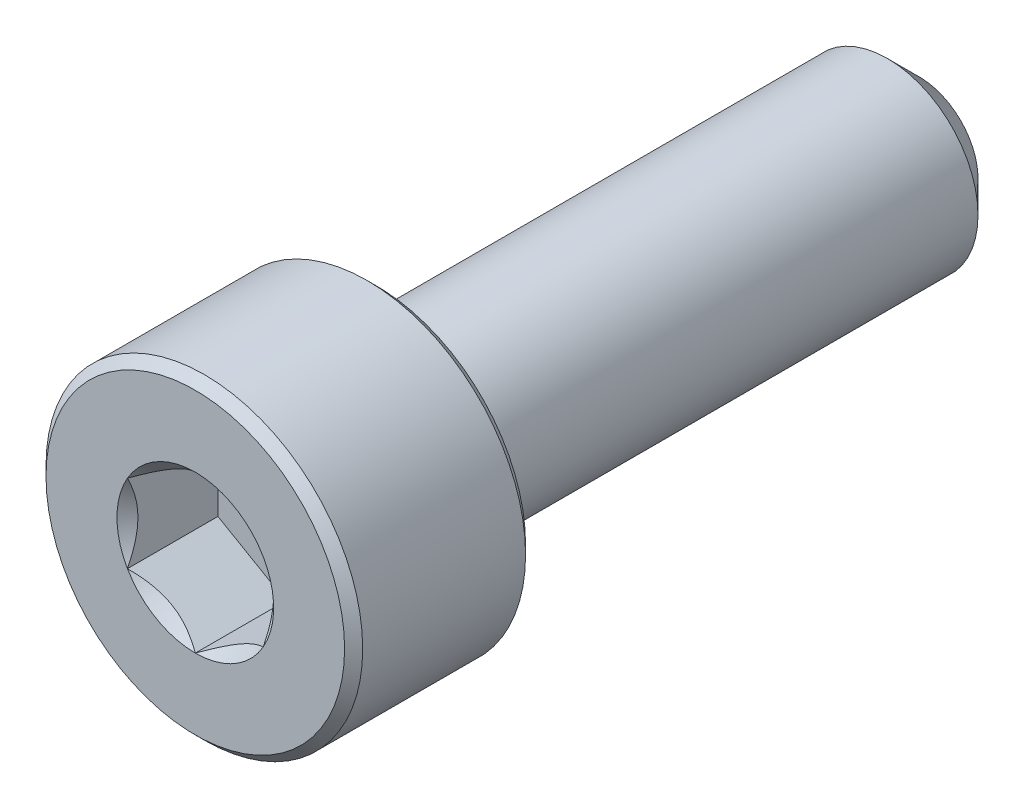
from build123d import *

# Parameters (mm, degrees)
CUT_EXTRUDE1_START = -2
CUT_EXTRUDE1_DEPTH = 2
SKETCH4_R          = 1.732050808
CUT_EXTRUDE2_DEPTH = 0.5
CUT_EXTRUDE2_TAPER = 45


with BuildPart() as part:
    # Sketch2 → Revolve1 (revolve)
    with BuildSketch(Plane(origin=(0, 0, 0), x_dir=(0, 0, -1), z_dir=(1, 0, 0))):
        Polygon((-7.8, 3.5), (-4.2, 3.5), (-4, 3.3), (-4, 2), (7.3, 2), (8, 1.3), (8, 0), (-8, 0), (-8, 3.3), align=None)
    revolve(axis=Axis((0, 0, -8), (0, 0, 1)))

    # Sketch3 → Cut-Extrude1 (cut)
    with BuildSketch(Plane.XY.offset(8).offset(CUT_EXTRUDE1_START)):
        Polygon((0, 1.732050808), (-1.5, 0.866025404), (-1.5, -0.866025404), (0, -1.732050808), (1.5, -0.866025404), (1.5, 0.866025404), align=None)
    extrude(amount=CUT_EXTRUDE1_DEPTH, mode=Mode.SUBTRACT)

    # Sketch4 → Cut-Extrude2 (cut)
    with BuildSketch(Plane.XY.offset(8)):
        Circle(SKETCH4_R)
    extrude(amount=-CUT_EXTRUDE2_DEPTH, taper=CUT_EXTRUDE2_TAPER, mode=Mode.SUBTRACT)


solid = part.part
